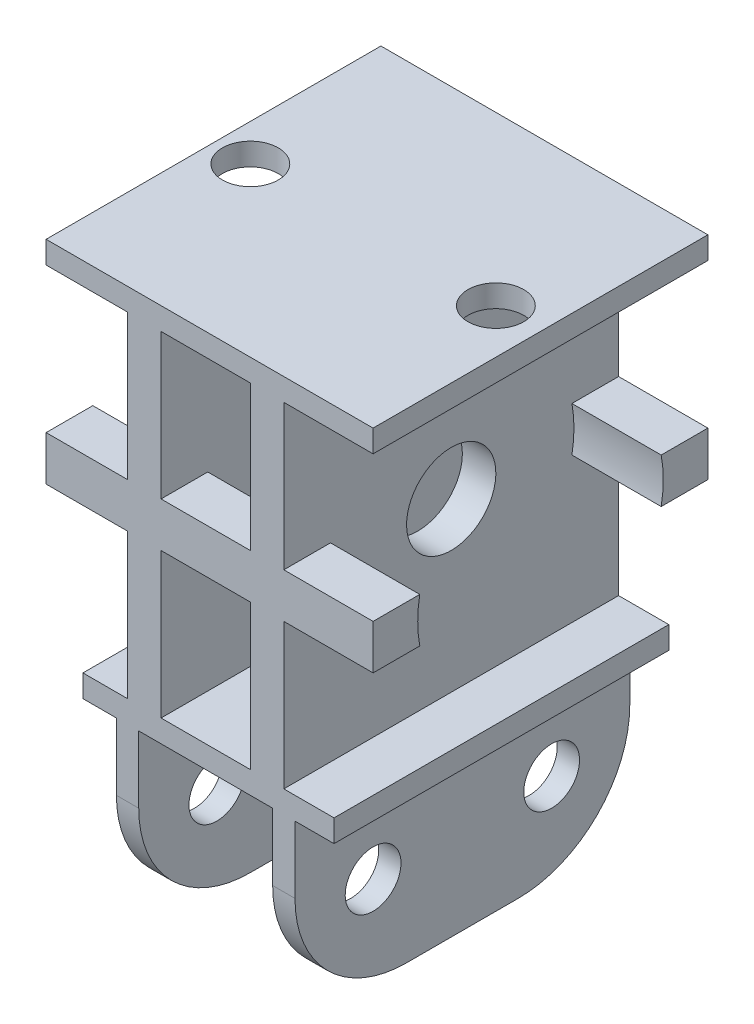
from build123d import *

# Parameters (mm, degrees)
CROQUIS1_W              = 8
CROQUIS1_H              = 13
SALIENTE_EXTRUIR1_DEPTH = 15
CROQUIS3_R              = 11
CORTAR_EXTRUIR1_DEPTH   = 15
CROQUIS4_R              = 2.5
CORTAR_EXTRUIR2_DEPTH   = 30
REDONDEO1_R             = 10
CROQUIS5_R              = 2.5
CORTAR_EXTRUIR3_DEPTH   = 2
SKETCH2_R               = 11
SKETCH2_R_2             = 4
BOSS_EXTRUDE1_DEPTH     = 3
SKETCH3_R               = 11
SKETCH3_R_2             = 4
BOSS_EXTRUDE2_DEPTH     = 3
SKETCH4_W               = 3.5
SKETCH4_H               = 2
SKETCH4_W_2             = 4
CUT_EXTRUDE1_DEPTH      = 31
SKETCH5_W               = 30
SKETCH5_H               = 19
CUT_EXTRUDE2_DEPTH      = 0.7


with BuildPart() as part:
    # Croquis1 → Saliente-Extruir1 (new body, symmetric)
    with BuildSketch(Plane.XY):
        Polygon((-15, -2), (-7, -2), (-7, -15), (-15, -15), (-15, -17), (-8, -17), (-8, -33), (-6, -33), (-6, -17), (6, -17), (6, -33), (8, -33), (8, -17), (15, -17), (15, -15), (7, -15), (7, -2), (15, -2), (15, 2), (7, 2), (7, 15), (15, 15), (15, 17), (-15, 17), (-15, 15), (-7, 15), (-7, 2), (-15, 2), align=None)
        with Locations((0, 8.5)):
            Rectangle(CROQUIS1_W, CROQUIS1_H, mode=Mode.SUBTRACT)
        with Locations((0, -8.5)):
            Rectangle(CROQUIS1_W, CROQUIS1_H, mode=Mode.SUBTRACT)
    extrude(amount=SALIENTE_EXTRUIR1_DEPTH, both=True)

    # Croquis3 → Cortar-Extruir1 (cut, symmetric)
    with BuildSketch(Plane(origin=(0, 0, 0), x_dir=(0, 0, -1), z_dir=(1, 0, 0))):
        Circle(CROQUIS3_R)
    extrude(amount=CORTAR_EXTRUIR1_DEPTH, both=True, mode=Mode.SUBTRACT)

    # Croquis4 → Cortar-Extruir2 (cut)
    with BuildSketch(Plane(origin=(8, 0, 0), x_dir=(0, 0, -1), z_dir=(1, 0, 0))):
        with Locations((-8, -25)):
            Circle(CROQUIS4_R)
        with Locations((8, -25)):
            Circle(CROQUIS4_R)
    extrude(amount=-CORTAR_EXTRUIR2_DEPTH, mode=Mode.SUBTRACT)

    # Redondeo1
    redondeo1_edges = [part.edges().sort_by_distance(p)[0] for p in [
        (7, -33, -15),
        (-7, -33, -15),
        (-7, -33, 15),
        (7, -33, 15),
    ]]
    fillet(redondeo1_edges, radius=REDONDEO1_R)

    # Croquis5 → Cortar-Extruir3 (cut)
    with BuildSketch(Plane(origin=(0, 17, 0), x_dir=(1, 0, 0), z_dir=(0, 1, 0))):
        with Locations((-11, 0)):
            Circle(CROQUIS5_R)
        with Locations((11, 0)):
            Circle(CROQUIS5_R)
    extrude(amount=-CORTAR_EXTRUIR3_DEPTH, mode=Mode.SUBTRACT)

    # Sketch2 → Boss-Extrude1 (add)
    with BuildSketch(Plane(origin=(7, 0, 0), x_dir=(0, 0, -1), z_dir=(1, 0, 0))):
        Circle(SKETCH2_R)
        Circle(SKETCH2_R_2, mode=Mode.SUBTRACT)
    extrude(amount=-BOSS_EXTRUDE1_DEPTH)

    # Sketch3 → Boss-Extrude2 (add)
    with BuildSketch(Plane.ZY.offset(7)):
        Circle(SKETCH3_R)
        Circle(SKETCH3_R_2, mode=Mode.SUBTRACT)
    extrude(amount=-BOSS_EXTRUDE2_DEPTH)

    # Sketch4 → Cut-Extrude1 (cut, through all)
    with BuildSketch(Plane(origin=(0, 0, -15), x_dir=(-1, 0, 0), z_dir=(0, 0, -1))):
        with Locations((-13.25, -16)):
            Rectangle(SKETCH4_W, SKETCH4_H)
        with Locations((13, -16)):
            Rectangle(SKETCH4_W_2, SKETCH4_H)
    extrude(amount=-CUT_EXTRUDE1_DEPTH, mode=Mode.SUBTRACT)

    # Sketch5 → Cut-Extrude2 (cut)
    with BuildSketch(Plane.ZY.offset(15)):
        with Locations((0, 7.5)):
            Rectangle(SKETCH5_W, SKETCH5_H)
    extrude(amount=-CUT_EXTRUDE2_DEPTH, mode=Mode.SUBTRACT)


solid = part.part
